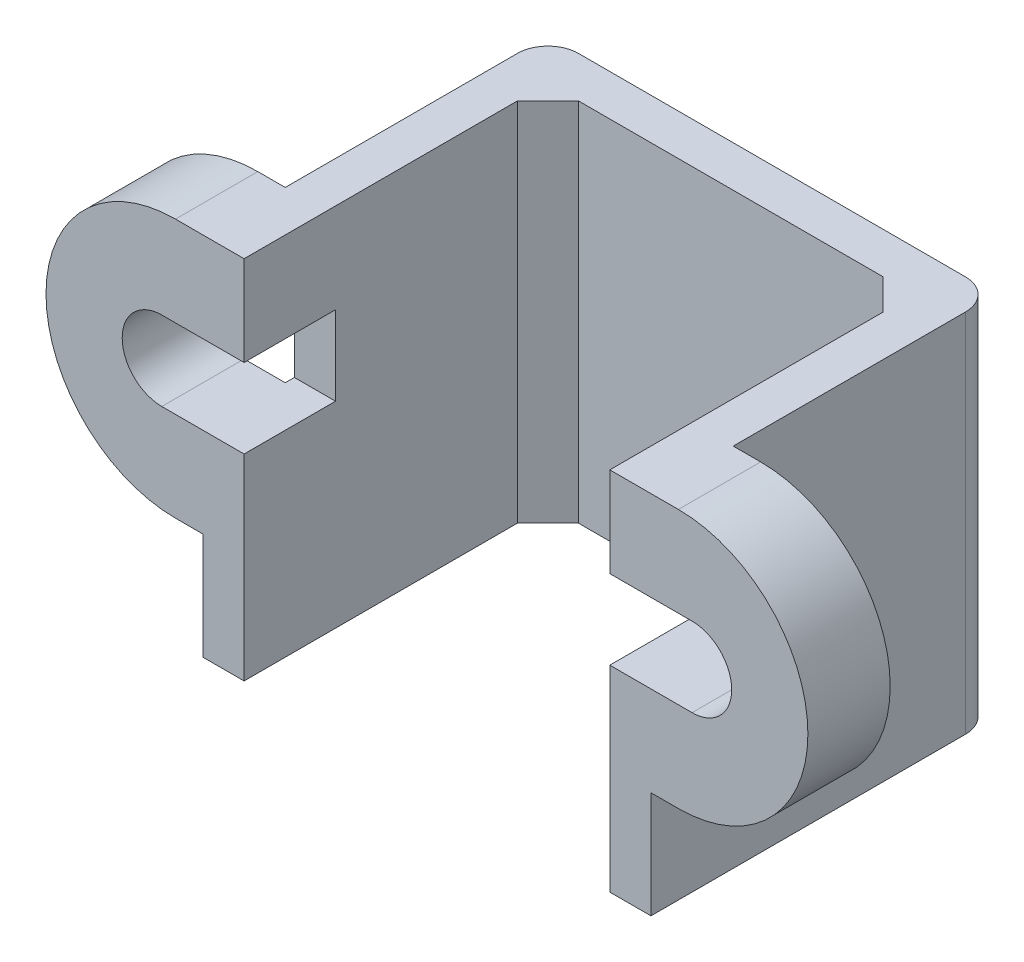
from build123d import *

# Parameters (mm, degrees)
SKETCH_1_W          = 12
SKETCH_1_H          = 12
EXTRUDE_1_DEPTH     = 1.35
SKETCH_2_W          = 11.32
SKETCH_2_H          = 12
EXTRUDE_2_DEPTH     = 1.35
EXTRUDE_3_DEPTH     = 2.7
CUT_EXTRUDE_1_DEPTH = 3
CHAMFER_1_SIZE      = 1
FILLET_1_R          = 1


with BuildPart() as part:
    # 草图1 → 凸台-拉伸1 (new body)
    with BuildSketch(Plane.XY):
        Rectangle(SKETCH_1_W, SKETCH_1_H)
    extrude(amount=EXTRUDE_1_DEPTH)

    # 草图2 → 凸台-拉伸2 (add)
    with BuildSketch(Plane.ZY.offset(6)):
        with Locations((5.66, 0)):
            Rectangle(SKETCH_2_W, SKETCH_2_H)
    extrude_2 = extrude(amount=EXTRUDE_2_DEPTH)

    # 草图3 → 凸台-拉伸3 (add)
    with BuildSketch(Plane.XY.offset(11.32)):
        with BuildLine():
            Line((-7.35, 6), (-8.25, 6))
            ThreePointArc((-8.25, 6), (-12.5, 1.75), (-8.25, -2.5))
            Line((-8.25, -2.5), (-7.35, -2.5))
            Line((-7.35, -2.5), (-7.35, 6))
        make_face()
    extrude_3 = extrude(amount=-EXTRUDE_3_DEPTH)

    # 草图4 → 切除-拉伸1 (cut)
    with BuildSketch(Plane.XY.offset(11.32)):
        with BuildLine():
            Line((-6, 3.05), (-8.7, 3.05))
            ThreePointArc((-8.7, 3.05), (-10, 1.75), (-8.7, 0.45))
            Line((-8.7, 0.45), (-6, 0.45))
            Line((-6, 0.45), (-6, 3.05))
        make_face()
    cut_extrude_1 = extrude(amount=-CUT_EXTRUDE_1_DEPTH, mode=Mode.SUBTRACT)

    # 镜向1: 凸台-拉伸2, 凸台-拉伸3, 切除-拉伸1 across plane
    add(extrude_2.mirror(Plane(origin=(0, 0, 0), x_dir=(0, 0, 1), z_dir=(1, 0, 0))))
    add(extrude_3.mirror(Plane(origin=(0, 0, 0), x_dir=(0, 0, 1), z_dir=(1, 0, 0))))
    add(cut_extrude_1.mirror(Plane(origin=(0, 0, 0), x_dir=(0, 0, 1), z_dir=(1, 0, 0))), mode=Mode.SUBTRACT)

    # 倒角1
    chamfer_1_edges = [part.edges().sort_by_distance(p)[0] for p in [
        (-6, 0, 1.35),
        (6, 0, 1.35),
    ]]
    chamfer(chamfer_1_edges, length=CHAMFER_1_SIZE)

    # 圆角1
    fillet_1_edges = [part.edges().sort_by_distance(p)[0] for p in [
        (-7.35, 0, 0),
        (7.35, 0, 0),
    ]]
    fillet(fillet_1_edges, radius=FILLET_1_R)


solid = part.part
